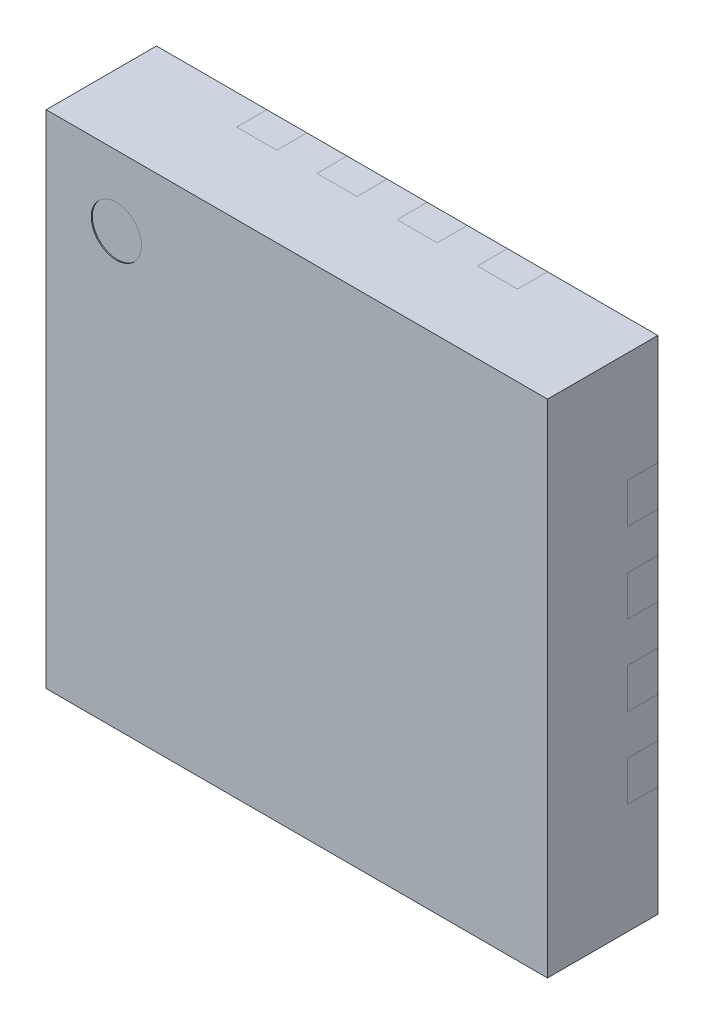
from build123d import *

# Parameters (mm, degrees)
SKETCH1_W              = 2.5
SKETCH1_H              = 2.5
BOSS_EXTRUDE1_DEPTH    = 0.55
SKETCH2_W              = 0.2
SKETCH2_H              = 0.15
CUT_EXTRUDE1_DEPTH     = 0.4
CIRPATTERN1_COUNT      = 4
SKETCH3_W              = 0.2
SKETCH3_H              = 0.4
BOSS_EXTRUDE2_DEPTH    = 0.15
BOSS_EXTRUDE2_2_DEPTH  = 0.15
BOSS_EXTRUDE2_3_DEPTH  = 0.15
BOSS_EXTRUDE2_4_DEPTH  = 0.15
SKETCH3_W_2            = 0.4
SKETCH3_H_2            = 0.2
BOSS_EXTRUDE2_5_DEPTH  = 0.15
BOSS_EXTRUDE2_6_DEPTH  = 0.15
BOSS_EXTRUDE2_7_DEPTH  = 0.15
BOSS_EXTRUDE2_8_DEPTH  = 0.15
BOSS_EXTRUDE2_9_DEPTH  = 0.15
BOSS_EXTRUDE2_10_DEPTH = 0.15
BOSS_EXTRUDE2_11_DEPTH = 0.15
BOSS_EXTRUDE2_12_DEPTH = 0.15
BOSS_EXTRUDE2_13_DEPTH = 0.15
BOSS_EXTRUDE2_14_DEPTH = 0.15
BOSS_EXTRUDE2_15_DEPTH = 0.15
BOSS_EXTRUDE2_16_DEPTH = 0.15
SKETCH4_R              = 0.125
CUT_EXTRUDE2_DEPTH     = 0.005


with BuildPart() as part:
    # Sketch1 → Boss-Extrude1 (new body)
    with BuildSketch(Plane.XY):
        Rectangle(SKETCH1_W, SKETCH1_H)
    extrude(amount=BOSS_EXTRUDE1_DEPTH)

    # Sketch2 → Cut-Extrude1 (cut)
    with BuildSketch(Plane.XZ.offset(1.25)):
        with Locations((0.6, -0.075)):
            Rectangle(SKETCH2_W, SKETCH2_H)
        with Locations((0.6, 0.075)):
            Rectangle(SKETCH2_W, SKETCH2_H)
        with Locations((0.2, -0.075)):
            Rectangle(SKETCH2_W, SKETCH2_H)
        with Locations((0.2, 0.075)):
            Rectangle(SKETCH2_W, SKETCH2_H)
        with Locations((-0.2, 0.075)):
            Rectangle(SKETCH2_W, SKETCH2_H)
        with Locations((-0.2, -0.075)):
            Rectangle(SKETCH2_W, SKETCH2_H)
        with Locations((-0.6, 0.075)):
            Rectangle(SKETCH2_W, SKETCH2_H)
        with Locations((-0.6, -0.075)):
            Rectangle(SKETCH2_W, SKETCH2_H)
    cut_extrude1 = extrude(amount=-CUT_EXTRUDE1_DEPTH, mode=Mode.SUBTRACT)

    # CirPattern1: Cut-Extrude1 ×4 about axis
    cirpattern1_axis = Axis((0, 0, 0), (0, 0, 1))
    for i in range(1, CIRPATTERN1_COUNT):
        add(cut_extrude1.rotate(cirpattern1_axis, i * 360 / CIRPATTERN1_COUNT), mode=Mode.SUBTRACT)

    # Sketch4 → Cut-Extrude2 (cut)
    with BuildSketch(Plane.XY.offset(0.55)):
        with Locations((-0.9, 0.9)):
            Circle(SKETCH4_R)
    extrude(amount=-CUT_EXTRUDE2_DEPTH, mode=Mode.SUBTRACT)


with BuildPart() as body_2:
    # Sketch3 → Boss-Extrude2 (new body)
    with BuildSketch(Plane(origin=(0, 0, 0.15), x_dir=(-1, 0, 0), z_dir=(0, 0, -1))):
        with Locations((-0.6, -1.05)):
            Rectangle(SKETCH3_W, SKETCH3_H)
    extrude(amount=BOSS_EXTRUDE2_DEPTH)


with BuildPart() as body_3:
    # Sketch3 → Boss-Extrude2 2 (new body)
    with BuildSketch(Plane(origin=(0, 0, 0.15), x_dir=(-1, 0, 0), z_dir=(0, 0, -1))):
        with Locations((-0.2, -1.05)):
            Rectangle(SKETCH3_W, SKETCH3_H)
    extrude(amount=BOSS_EXTRUDE2_2_DEPTH)


with BuildPart() as body_4:
    # Sketch3 → Boss-Extrude2 3 (new body)
    with BuildSketch(Plane(origin=(0, 0, 0.15), x_dir=(-1, 0, 0), z_dir=(0, 0, -1))):
        with Locations((0.2, -1.05)):
            Rectangle(SKETCH3_W, SKETCH3_H)
    extrude(amount=BOSS_EXTRUDE2_3_DEPTH)


with BuildPart() as body_5:
    # Sketch3 → Boss-Extrude2 4 (new body)
    with BuildSketch(Plane(origin=(0, 0, 0.15), x_dir=(-1, 0, 0), z_dir=(0, 0, -1))):
        with Locations((0.6, -1.05)):
            Rectangle(SKETCH3_W, SKETCH3_H)
    extrude(amount=BOSS_EXTRUDE2_4_DEPTH)


with BuildPart() as body_6:
    # Sketch3 → Boss-Extrude2 5 (new body)
    with BuildSketch(Plane(origin=(0, 0, 0.15), x_dir=(-1, 0, 0), z_dir=(0, 0, -1))):
        with Locations((1.05, -0.6)):
            Rectangle(SKETCH3_W_2, SKETCH3_H_2)
    extrude(amount=BOSS_EXTRUDE2_5_DEPTH)


with BuildPart() as body_7:
    # Sketch3 → Boss-Extrude2 6 (new body)
    with BuildSketch(Plane(origin=(0, 0, 0.15), x_dir=(-1, 0, 0), z_dir=(0, 0, -1))):
        with Locations((1.05, -0.2)):
            Rectangle(SKETCH3_W_2, SKETCH3_H_2)
    extrude(amount=BOSS_EXTRUDE2_6_DEPTH)


with BuildPart() as body_8:
    # Sketch3 → Boss-Extrude2 7 (new body)
    with BuildSketch(Plane(origin=(0, 0, 0.15), x_dir=(-1, 0, 0), z_dir=(0, 0, -1))):
        with Locations((1.05, 0.2)):
            Rectangle(SKETCH3_W_2, SKETCH3_H_2)
    extrude(amount=BOSS_EXTRUDE2_7_DEPTH)


with BuildPart() as body_9:
    # Sketch3 → Boss-Extrude2 8 (new body)
    with BuildSketch(Plane(origin=(0, 0, 0.15), x_dir=(-1, 0, 0), z_dir=(0, 0, -1))):
        with Locations((1.05, 0.6)):
            Rectangle(SKETCH3_W_2, SKETCH3_H_2)
    extrude(amount=BOSS_EXTRUDE2_8_DEPTH)


with BuildPart() as body_10:
    # Sketch3 → Boss-Extrude2 9 (new body)
    with BuildSketch(Plane(origin=(0, 0, 0.15), x_dir=(-1, 0, 0), z_dir=(0, 0, -1))):
        with Locations((0.6, 1.05)):
            Rectangle(SKETCH3_W, SKETCH3_H)
    extrude(amount=BOSS_EXTRUDE2_9_DEPTH)


with BuildPart() as body_11:
    # Sketch3 → Boss-Extrude2 10 (new body)
    with BuildSketch(Plane(origin=(0, 0, 0.15), x_dir=(-1, 0, 0), z_dir=(0, 0, -1))):
        with Locations((0.2, 1.05)):
            Rectangle(SKETCH3_W, SKETCH3_H)
    extrude(amount=BOSS_EXTRUDE2_10_DEPTH)


with BuildPart() as body_12:
    # Sketch3 → Boss-Extrude2 11 (new body)
    with BuildSketch(Plane(origin=(0, 0, 0.15), x_dir=(-1, 0, 0), z_dir=(0, 0, -1))):
        with Locations((-0.2, 1.05)):
            Rectangle(SKETCH3_W, SKETCH3_H)
    extrude(amount=BOSS_EXTRUDE2_11_DEPTH)


with BuildPart() as body_13:
    # Sketch3 → Boss-Extrude2 12 (new body)
    with BuildSketch(Plane(origin=(0, 0, 0.15), x_dir=(-1, 0, 0), z_dir=(0, 0, -1))):
        with Locations((-0.6, 1.05)):
            Rectangle(SKETCH3_W, SKETCH3_H)
    extrude(amount=BOSS_EXTRUDE2_12_DEPTH)


with BuildPart() as body_14:
    # Sketch3 → Boss-Extrude2 13 (new body)
    with BuildSketch(Plane(origin=(0, 0, 0.15), x_dir=(-1, 0, 0), z_dir=(0, 0, -1))):
        with Locations((-1.05, 0.6)):
            Rectangle(SKETCH3_W_2, SKETCH3_H_2)
    extrude(amount=BOSS_EXTRUDE2_13_DEPTH)


with BuildPart() as body_15:
    # Sketch3 → Boss-Extrude2 14 (new body)
    with BuildSketch(Plane(origin=(0, 0, 0.15), x_dir=(-1, 0, 0), z_dir=(0, 0, -1))):
        with Locations((-1.05, 0.2)):
            Rectangle(SKETCH3_W_2, SKETCH3_H_2)
    extrude(amount=BOSS_EXTRUDE2_14_DEPTH)


with BuildPart() as body_16:
    # Sketch3 → Boss-Extrude2 15 (new body)
    with BuildSketch(Plane(origin=(0, 0, 0.15), x_dir=(-1, 0, 0), z_dir=(0, 0, -1))):
        with Locations((-1.05, -0.2)):
            Rectangle(SKETCH3_W_2, SKETCH3_H_2)
    extrude(amount=BOSS_EXTRUDE2_15_DEPTH)


with BuildPart() as body_17:
    # Sketch3 → Boss-Extrude2 16 (new body)
    with BuildSketch(Plane(origin=(0, 0, 0.15), x_dir=(-1, 0, 0), z_dir=(0, 0, -1))):
        with Locations((-1.05, -0.6)):
            Rectangle(SKETCH3_W_2, SKETCH3_H_2)
    extrude(amount=BOSS_EXTRUDE2_16_DEPTH)


solid = Compound([part.part, body_2.part, body_3.part, body_4.part, body_5.part, body_6.part, body_7.part, body_8.part, body_9.part, body_10.part, body_11.part, body_12.part, body_13.part, body_14.part, body_15.part, body_16.part, body_17.part])
